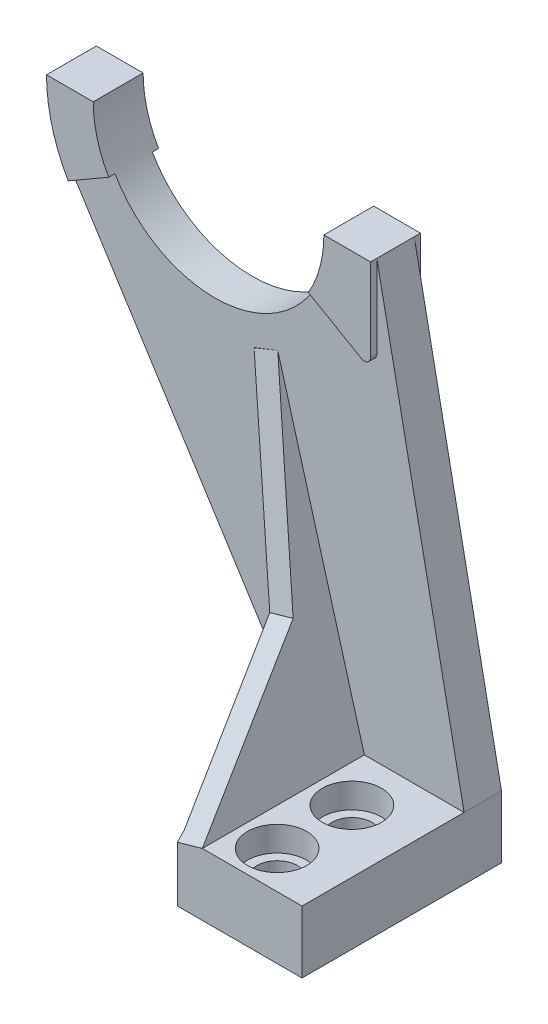
from build123d import *

# Parameters (mm, degrees)
SALIENTE_EXTRUIR1_DEPTH = 9.525
CROQUIS2_W              = 31.75
CROQUIS2_H              = 15.875
SALIENTE_EXTRUIR2_DEPTH = 41.275
CROQUIS3_R              = 5.159375
CORTAR_EXTRUIR1_DEPTH   = 133.943055
CROQUIS4_R              = 7.540625
CORTAR_EXTRUIR2_DEPTH   = 6.35
SALIENTE_EXTRUIR5_DEPTH = 6.35
REDONDEO1_R             = 1.5875
REDONDEO4_R             = 1.5875
SALIENTE_EXTRUIR8_DEPTH = 41.275
CORTAR_EXTRUIR4_DEPTH   = 41.275


with BuildPart() as part:
    # Croquis1 → Saliente-Extruir1 (new body)
    with BuildSketch(Plane.XY):
        with BuildLine():
            Line((-52.3875, 63.5), (-40.48125, 63.5))
            ThreePointArc((-40.48125, 63.5), (-11.1125, 34.13125), (18.25625, 63.5))
            Line((18.25625, 63.5), (30.1625, 63.5))
            Line((30.1625, 63.5), (52.3875, -47.625))
            Line((52.3875, -47.625), (52.3875, -63.5))
            Line((52.3875, -63.5), (20.6375, -63.5))
            Line((20.6375, -63.5), (-46.857699, 42.8625))
            ThreePointArc((-46.857699, 42.8625), (-50.981088, 52.817244), (-52.3875, 63.5))
        make_face()
    extrude(amount=SALIENTE_EXTRUIR1_DEPTH)

    # Croquis2 → Saliente-Extruir2 (add)
    with BuildSketch(Plane.XY.offset(9.525)):
        with Locations((36.5125, -55.5625)):
            Rectangle(CROQUIS2_W, CROQUIS2_H)
    extrude(amount=SALIENTE_EXTRUIR2_DEPTH)

    # Croquis3 → Cortar-Extruir1 (cut, through all)
    with BuildSketch(Plane(origin=(0, -47.625, 0), x_dir=(1, 0, 0), z_dir=(0, 1, 0))):
        with Locations(Location((36.5125, -41.275, 0), (0, 0, 270))):
            Circle(CROQUIS3_R)
        with Locations(Location((36.5125, -22.225, 0), (0, 0, 270))):
            Circle(CROQUIS3_R)
    extrude(amount=-CORTAR_EXTRUIR1_DEPTH, mode=Mode.SUBTRACT)

    # Croquis4 → Cortar-Extruir2 (cut)
    with BuildSketch(Plane(origin=(0, -47.625, 0), x_dir=(1, 0, 0), z_dir=(0, 1, 0))):
        with Locations(Location((36.5125, -22.225, 0), (0, 0, 270))):
            Circle(CROQUIS4_R)
        with Locations(Location((36.5125, -41.275, 0), (0, 0, 270))):
            Circle(CROQUIS4_R)
    extrude(amount=-CORTAR_EXTRUIR2_DEPTH, mode=Mode.SUBTRACT)

    # Croquis8 → Saliente-Extruir5 (add, symmetric)
    with BuildSketch(Plane.XY.offset(4.7625)):
        with BuildLine():
            Line((-52.3875, 63.5), (-40.48125, 63.5))
            ThreePointArc((-40.48125, 63.5), (-39.480534, 55.898808), (-36.546584, 48.815625))
            Line((-36.546584, 48.815625), (-46.857699, 42.8625))
            ThreePointArc((-46.857699, 42.8625), (-50.981088, 52.817244), (-52.3875, 63.5))
        make_face()
        with BuildLine():
            ThreePointArc((14.321584, 48.815625), (17.255534, 55.898808), (18.25625, 63.5))
            Line((18.25625, 63.5), (30.1625, 63.5))
            Line((30.1625, 63.5), (30.1625, 39.669868))
            Line((30.1625, 39.669868), (14.321584, 48.815625))
        make_face()
    extrude(amount=SALIENTE_EXTRUIR5_DEPTH, both=True)

    # Redondeo1
    redondeo1_edges = [part.edges().sort_by_distance(p)[0] for p in [
        (30.1625, 39.669868, 10.31875),
    ]]
    fillet(redondeo1_edges, radius=REDONDEO1_R)

    # Redondeo4
    redondeo4_edges = [part.edges().sort_by_distance(p)[0] for p in [
        (30.1625, 39.669868, -0.79375),
    ]]
    fillet(redondeo4_edges, radius=REDONDEO4_R)

    # Croquis9 → Saliente-Extruir8 (add)
    with BuildSketch(Plane.XY.offset(9.525)):
        Polygon((-0.982547, 28.253318), (20.6375, -47.625), (23.8125, -47.625), (26.9875, -47.625), (4.929446, 30.570825), (1.97345, 29.412071), align=None)
    extrude(amount=SALIENTE_EXTRUIR8_DEPTH)

    # Croquis12 → Cortar-Extruir4 (cut)
    with BuildSketch(Plane(origin=(12.554117, 3.541358, 0), x_dir=(0, 0, -1), z_dir=(0.9624406031715071, 0.27149233021738517, 0))):
        Polygon((-9.525, 28.084296), (-50.8, 28.084296), (-50.8, -53.163133), (-19.05, -21.413133), align=None)
    extrude(amount=-CORTAR_EXTRUIR4_DEPTH, mode=Mode.SUBTRACT)


solid = part.part
